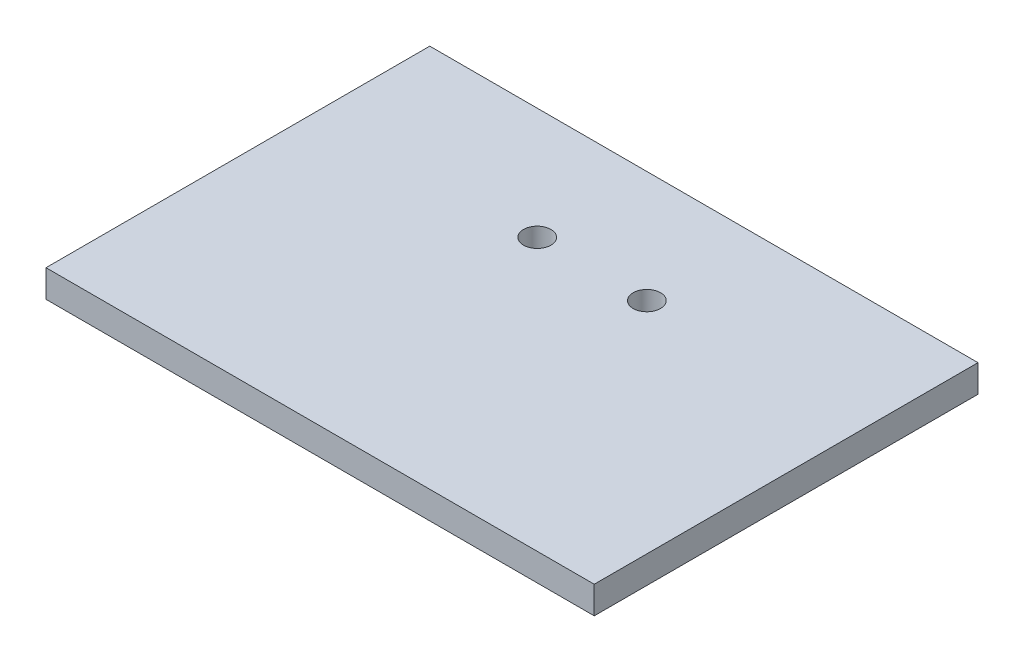
from build123d import *

# Parameters (mm, degrees)
SKETCH1_W           = 63.5
SKETCH1_H           = 3.175
BOSS_EXTRUDE1_DEPTH = 44.45
SKETCH2_R           = 1.5875
CUT_EXTRUDE1_DEPTH  = 4.175


with BuildPart() as part:
    # Sketch1 → Boss-Extrude1 (new body)
    with BuildSketch(Plane.XY):
        with Locations((31.75, 1.5875)):
            Rectangle(SKETCH1_W, SKETCH1_H)
    extrude(amount=BOSS_EXTRUDE1_DEPTH)

    # Sketch2 → Cut-Extrude1 (cut, through all)
    with BuildSketch(Plane(origin=(0, 3.175, 0), x_dir=(1, 0, 0), z_dir=(0, 1, 0))):
        with Locations((25.4, -12.954)):
            Circle(SKETCH2_R)
        with Locations((38.1, -12.954)):
            Circle(SKETCH2_R)
    extrude(amount=-CUT_EXTRUDE1_DEPTH, mode=Mode.SUBTRACT)


solid = part.part
